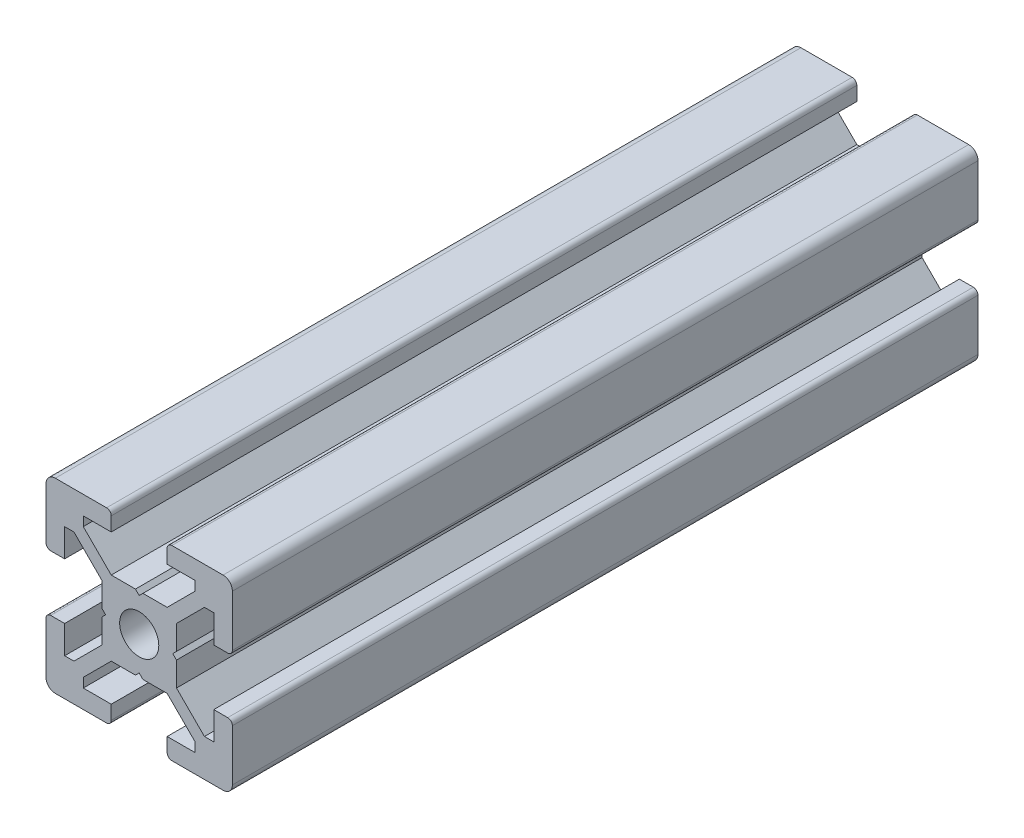
from build123d import *

# Parameters (mm, degrees)
SCHIZZO1_R                   = 2.1
ESTRUSIONE_ESTRUSIONE1_DEPTH = 80


with BuildPart() as part:
    # Schizzo1 → Estrusione-Estrusione1 (new body)
    with BuildSketch(Plane.XY):
        with BuildLine():
            Line((-3.6, 0), (-4, 0.4))
            Line((-4, 0.4), (-4, 3))
            Line((-4, 3), (-7, 6))
            Line((-7, 6), (-8, 6))
            Line((-8, 6), (-8, 3))
            Line((-8, 3), (-9.5, 3))
            ThreePointArc((-9.5, 3), (-9.853553391, 3.146446609), (-10, 3.5))
            Line((-10, 3.5), (-10, 9))
            ThreePointArc((-10, 9), (-9.707106781, 9.707106781), (-9, 10))
            Line((-9, 10), (-3.5, 10))
            ThreePointArc((-3.5, 10), (-3.146446609, 9.853553391), (-3, 9.5))
            Line((-3, 9.5), (-3, 8))
            Line((-3, 8), (-6, 8))
            Line((-6, 8), (-6, 7))
            Line((-6, 7), (-3, 4))
            Line((-3, 4), (-0.4, 4))
            Line((-0.4, 4), (0, 3.6))
            Line((0, 3.6), (0.4, 4))
            Line((0.4, 4), (3, 4))
            Line((3, 4), (6, 7))
            Line((6, 7), (6, 8))
            Line((6, 8), (3, 8))
            Line((3, 8), (3, 9.5))
            ThreePointArc((3, 9.5), (3.146446609, 9.853553391), (3.5, 10))
            Line((3.5, 10), (9, 10))
            ThreePointArc((9, 10), (9.707106781, 9.707106781), (10, 9))
            Line((10, 9), (10, 3.5))
            ThreePointArc((10, 3.5), (9.853553391, 3.146446609), (9.5, 3))
            Line((9.5, 3), (8, 3))
            Line((8, 3), (8, 6))
            Line((8, 6), (7, 6))
            Line((7, 6), (4, 3))
            Line((4, 3), (4, 0.4))
            Line((4, 0.4), (3.6, 0))
            Line((3.6, 0), (4, -0.4))
            Line((4, -0.4), (4, -3))
            Line((4, -3), (7, -6))
            Line((7, -6), (8, -6))
            Line((8, -6), (8, -3))
            Line((8, -3), (9.5, -3))
            ThreePointArc((9.5, -3), (9.853553391, -3.146446609), (10, -3.5))
            Line((10, -3.5), (10, -9))
            ThreePointArc((10, -9), (9.707106781, -9.707106781), (9, -10))
            Line((9, -10), (3.5, -10))
            ThreePointArc((3.5, -10), (3.146446609, -9.853553391), (3, -9.5))
            Line((3, -9.5), (3, -8))
            Line((3, -8), (6, -8))
            Line((6, -8), (6, -7))
            Line((6, -7), (3, -4))
            Line((3, -4), (0.4, -4))
            Line((0.4, -4), (0, -3.6))
            Line((0, -3.6), (-0.4, -4))
            Line((-0.4, -4), (-3, -4))
            Line((-3, -4), (-6, -7))
            Line((-6, -7), (-6, -8))
            Line((-6, -8), (-3, -8))
            Line((-3, -8), (-3, -9.5))
            ThreePointArc((-3, -9.5), (-3.146446609, -9.853553391), (-3.5, -10))
            Line((-3.5, -10), (-9, -10))
            ThreePointArc((-9, -10), (-9.707106781, -9.707106781), (-10, -9))
            Line((-10, -9), (-10, -3.5))
            ThreePointArc((-10, -3.5), (-9.853553391, -3.146446609), (-9.5, -3))
            Line((-9.5, -3), (-8, -3))
            Line((-8, -3), (-8, -6))
            Line((-8, -6), (-7, -6))
            Line((-7, -6), (-4, -3))
            Line((-4, -3), (-4, -0.4))
            Line((-4, -0.4), (-3.6, 0))
        make_face()
        Circle(SCHIZZO1_R, mode=Mode.SUBTRACT)
    extrude(amount=ESTRUSIONE_ESTRUSIONE1_DEPTH)


solid = part.part
